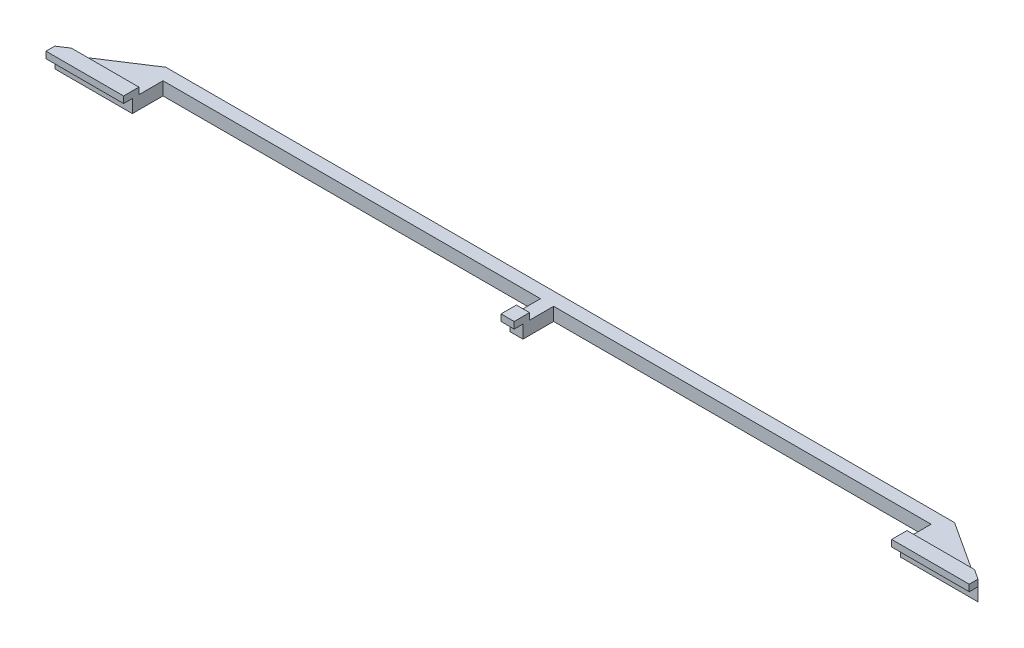
from build123d import *

# Parameters (mm, degrees)
SKETCH1_W           = 900
SKETCH1_H           = 30
BOSS_EXTRUDE1_DEPTH = 30
SKETCH2_W           = 15
SKETCH2_H           = 100
BOSS_EXTRUDE2_DEPTH = 30
SKETCH3_W           = 15
SKETCH3_H           = 15
BOSS_EXTRUDE3_DEPTH = 15
SKETCH4_W           = 177.04771777
SKETCH4_H           = 15
BOSS_EXTRUDE4_DEPTH = 20


with BuildPart() as part:
    # Sketch1 → Boss-Extrude1 (new body)
    with BuildSketch(Plane(origin=(0, 0, 0), x_dir=(1, 0, 0), z_dir=(0, 1, 0))):
        Rectangle(SKETCH1_W, SKETCH1_H)
    extrude(amount=BOSS_EXTRUDE1_DEPTH)

    # Sketch2 → Boss-Extrude2 (add)
    with BuildSketch(Plane(origin=(0, 30, 0), x_dir=(1, 0, 0), z_dir=(0, 1, 0))):
        Polygon((-450, 15), (-603.496801426, -85), (-426.449083656, -85), (-426.449083656, 15), align=None)
        with Locations((442.5, -35)):
            Rectangle(SKETCH2_W, SKETCH2_H)
    extrude(amount=-BOSS_EXTRUDE2_DEPTH)

    # Sketch3 → Boss-Extrude3 (add)
    with BuildSketch(Plane(origin=(0, 30, 0), x_dir=(1, 0, 0), z_dir=(0, 1, 0))):
        Polygon((-603.496801426, -85), (-580.472281212, -70), (-426.449083656, -70), (-426.449083656, -85), align=None)
        with Locations((442.5, -77.5)):
            Rectangle(SKETCH3_W, SKETCH3_H)
    extrude(amount=BOSS_EXTRUDE3_DEPTH)

    # Sketch4 → Boss-Extrude4 (add)
    with BuildSketch(Plane.XY.offset(85)):
        with Locations((-514.972942541, 37.5)):
            Rectangle(SKETCH4_W, SKETCH4_H)
        Polygon((435, 45), (450, 45), (450, 30), (435, 29.894509732), align=None)
    extrude(amount=BOSS_EXTRUDE4_DEPTH)

    # Mirror1: part across plane


with BuildPart() as part_1:
    add(part.part)
    add(part.part.mirror(Plane(origin=(450, 30, -15), x_dir=(0, 0, 1), z_dir=(-1, 0, 0))))


solid = part_1.part
